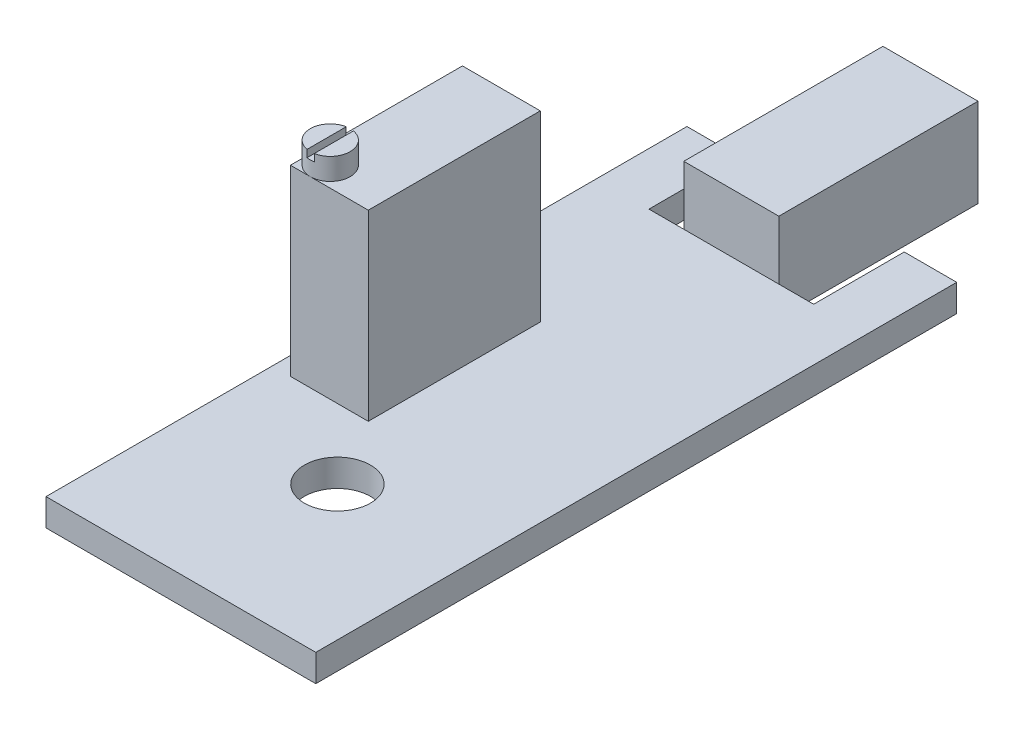
from build123d import *

# Parameters (mm, degrees)
SKETCH1_R                = 1.825
BOSS_EXTRUDE1_DEPTH      = 0.75
BOSS_EXTRUDE2_DEPTH      = 4
BOSS_EXTRUDE2_DEPTH_BACK = 0.9
SKETCH1_4_W              = 5.25
SKETCH1_4_H              = 11
SKETCH2_W                = 4.3
SKETCH2_H                = 9.5
BOSS_EXTRUDE3_DEPTH      = 10.1
SKETCH3_R                = 1.1
BOSS_EXTRUDE4_DEPTH      = 1.2
CUT_EXTRUDE1_START       = -0.4
CUT_EXTRUDE1_DEPTH       = 0.4


with BuildPart() as part:
    # Sketch1 → Boss-Extrude1 (new, symmetric)
    with BuildSketch(Plane(origin=(0, 0, 0), x_dir=(1, 0, 0), z_dir=(0, 1, 0))):
        Polygon((7.45, -17.7), (7.45, 17.7), (4.55, 17.7), (4.55, 12.7), (2.625, 12.7), (-2.625, 12.7), (-4.55, 12.7), (-4.55, 17.7), (-7.45, 17.7), (-7.45, -17.7), align=None)
        with Locations((0, -9.055)):
            Circle(SKETCH1_R, mode=Mode.SUBTRACT)
    extrude(amount=BOSS_EXTRUDE1_DEPTH, both=True)

    # Sketch1_4 → Boss-Extrude2 (add, two sides: drawn at the far end of the back side and taken through both)
    with BuildSketch(Plane(origin=(0, 0, 0), x_dir=(1, 0, 0), z_dir=(0, 1, 0)).offset(-BOSS_EXTRUDE2_DEPTH_BACK)):
        with Locations((0, 18.2)):
            Rectangle(SKETCH1_4_W, SKETCH1_4_H)
    extrude(amount=BOSS_EXTRUDE2_DEPTH + BOSS_EXTRUDE2_DEPTH_BACK)

    # Sketch2 → Boss-Extrude3 (add)
    with BuildSketch(Plane(origin=(0, 0.75, 0), x_dir=(1, 0, 0), z_dir=(0, 1, 0))):
        with Locations((-4.3, -0.45)):
            Rectangle(SKETCH2_W, SKETCH2_H)
    extrude(amount=BOSS_EXTRUDE3_DEPTH)

    # Sketch3 → Boss-Extrude4 (add)
    with BuildSketch(Plane(origin=(0, 10.85, 0), x_dir=(1, 0, 0), z_dir=(0, 1, 0))):
        with Locations((-5.35, -4.1)):
            Circle(SKETCH3_R)
    extrude(amount=BOSS_EXTRUDE4_DEPTH)

    # Sketch4 → Cut-Extrude1 (cut)
    with BuildSketch(Plane(origin=(0, 12.05, 0), x_dir=(1, 0, 0), z_dir=(0, 1, 0)).offset(CUT_EXTRUDE1_START)):
        with BuildLine():
            Line((-5.15, -3.018334617), (-5.15, -5.181665383))
            ThreePointArc((-5.15, -5.181665383), (-5.35, -5.2), (-5.55, -5.181665383))
            Line((-5.55, -5.181665383), (-5.55, -3.018334617))
            ThreePointArc((-5.55, -3.018334617), (-5.35, -3), (-5.15, -3.018334617))
        make_face()
    extrude(amount=CUT_EXTRUDE1_DEPTH, mode=Mode.SUBTRACT)


solid = part.part
